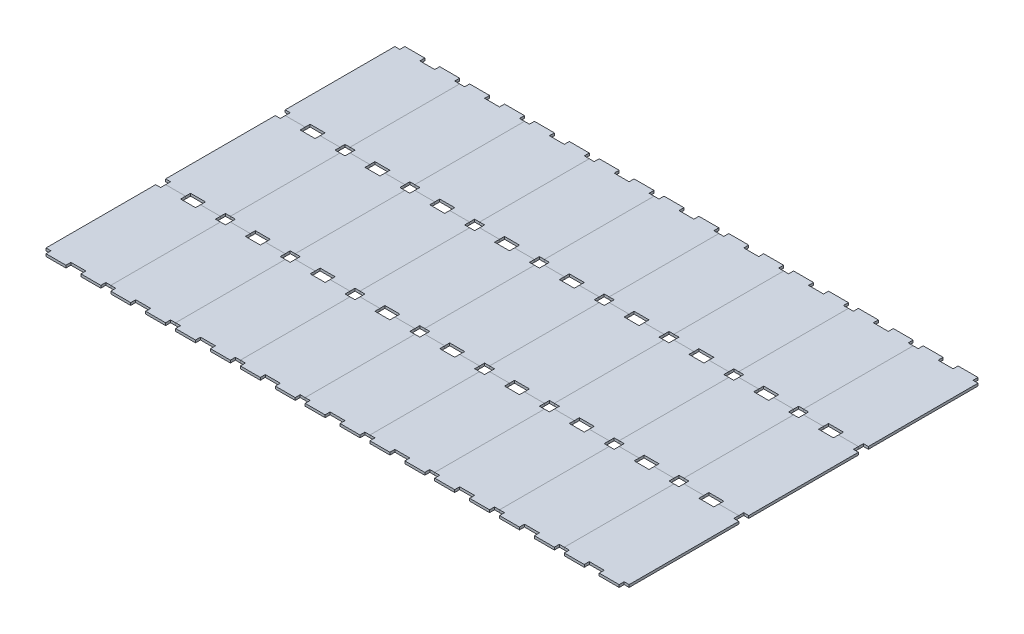
from build123d import *

# Parameters (mm, degrees)
SKETCH1_W           = 82.55
SKETCH1_H           = 152.4
BOSS_EXTRUDE1_DEPTH = 3.175
SKETCH2_W           = 6.35
SKETCH2_H           = 6.35
SKETCH2_W_2         = 9.525
CUT_EXTRUDE1_DEPTH  = 4.175
LPATTERN1_COUNT     = 9
LPATTERN1_PITCH     = 82.55
LPATTERN1_2_COUNT   = 3
LPATTERN1_2_PITCH   = 152.4


with BuildPart() as part:
    # Sketch1 → Boss-Extrude1 (new body)
    with BuildSketch(Plane(origin=(0, 0, 0), x_dir=(1, 0, 0), z_dir=(0, 1, 0))):
        Rectangle(SKETCH1_W, SKETCH1_H)
    extrude(amount=BOSS_EXTRUDE1_DEPTH)

    # Sketch2 → Cut-Extrude1 (cut, through all)
    with BuildSketch(Plane(origin=(0, 3.175, 0), x_dir=(1, 0, 0), z_dir=(0, 1, 0))):
        with Locations((-38.1, -73.025)):
            Rectangle(SKETCH2_W, SKETCH2_H)
        with Locations((-4.7625, -73.025)):
            Rectangle(SKETCH2_W_2, SKETCH2_H)
        with Locations((4.7625, -73.025)):
            Rectangle(SKETCH2_W_2, SKETCH2_H)
        with Locations((38.1, -73.025)):
            Rectangle(SKETCH2_W, SKETCH2_H)
    cut_extrude1 = extrude(amount=-CUT_EXTRUDE1_DEPTH, mode=Mode.SUBTRACT)

    # Mirror1: Cut-Extrude1 across plane
    add(cut_extrude1.mirror(Plane.XY), mode=Mode.SUBTRACT)


with BuildPart() as lpattern1_1:
    # LPattern1: pattern copy
    add(part.part.moved(Location(Vector(1, 0, 0) * (1 * LPATTERN1_PITCH))))


with BuildPart() as lpattern1_2:
    # LPattern1: pattern copy
    add(part.part.moved(Location(Vector(1, 0, 0) * (2 * LPATTERN1_PITCH))))


with BuildPart() as lpattern1_3:
    # LPattern1: pattern copy
    add(part.part.moved(Location(Vector(1, 0, 0) * (3 * LPATTERN1_PITCH))))


with BuildPart() as lpattern1_4:
    # LPattern1: pattern copy
    add(part.part.moved(Location(Vector(1, 0, 0) * (4 * LPATTERN1_PITCH))))


with BuildPart() as lpattern1_5:
    # LPattern1: pattern copy
    add(part.part.moved(Location(Vector(1, 0, 0) * (5 * LPATTERN1_PITCH))))


with BuildPart() as lpattern1_6:
    # LPattern1: pattern copy
    add(part.part.moved(Location(Vector(1, 0, 0) * (6 * LPATTERN1_PITCH))))


with BuildPart() as lpattern1_7:
    # LPattern1: pattern copy
    add(part.part.moved(Location(Vector(1, 0, 0) * (7 * LPATTERN1_PITCH))))


with BuildPart() as lpattern1_8:
    # LPattern1: pattern copy
    add(part.part.moved(Location(Vector(1, 0, 0) * (8 * LPATTERN1_PITCH))))


with BuildPart() as lpattern1_2_1:
    # LPattern1 2: pattern copy
    add(part.part.moved(Location(Vector(0, 0, 1) * (1 * LPATTERN1_2_PITCH))))


with BuildPart() as lpattern1_2_2:
    # LPattern1 2: pattern copy
    add(part.part.moved(Location(Vector(0, 0, 1) * (2 * LPATTERN1_2_PITCH))))


with BuildPart() as lpattern1_2_3:
    # LPattern1 2: pattern copy
    add(lpattern1_1.part.moved(Location(Vector(0, 0, 1) * (1 * LPATTERN1_2_PITCH))))


with BuildPart() as lpattern1_2_4:
    # LPattern1 2: pattern copy
    add(lpattern1_1.part.moved(Location(Vector(0, 0, 1) * (2 * LPATTERN1_2_PITCH))))


with BuildPart() as lpattern1_2_5:
    # LPattern1 2: pattern copy
    add(lpattern1_2.part.moved(Location(Vector(0, 0, 1) * (1 * LPATTERN1_2_PITCH))))


with BuildPart() as lpattern1_2_6:
    # LPattern1 2: pattern copy
    add(lpattern1_2.part.moved(Location(Vector(0, 0, 1) * (2 * LPATTERN1_2_PITCH))))


with BuildPart() as lpattern1_2_7:
    # LPattern1 2: pattern copy
    add(lpattern1_3.part.moved(Location(Vector(0, 0, 1) * (1 * LPATTERN1_2_PITCH))))


with BuildPart() as lpattern1_2_8:
    # LPattern1 2: pattern copy
    add(lpattern1_3.part.moved(Location(Vector(0, 0, 1) * (2 * LPATTERN1_2_PITCH))))


with BuildPart() as lpattern1_2_9:
    # LPattern1 2: pattern copy
    add(lpattern1_4.part.moved(Location(Vector(0, 0, 1) * (1 * LPATTERN1_2_PITCH))))


with BuildPart() as lpattern1_2_10:
    # LPattern1 2: pattern copy
    add(lpattern1_4.part.moved(Location(Vector(0, 0, 1) * (2 * LPATTERN1_2_PITCH))))


with BuildPart() as lpattern1_2_11:
    # LPattern1 2: pattern copy
    add(lpattern1_5.part.moved(Location(Vector(0, 0, 1) * (1 * LPATTERN1_2_PITCH))))


with BuildPart() as lpattern1_2_12:
    # LPattern1 2: pattern copy
    add(lpattern1_5.part.moved(Location(Vector(0, 0, 1) * (2 * LPATTERN1_2_PITCH))))


with BuildPart() as lpattern1_2_13:
    # LPattern1 2: pattern copy
    add(lpattern1_6.part.moved(Location(Vector(0, 0, 1) * (1 * LPATTERN1_2_PITCH))))


with BuildPart() as lpattern1_2_14:
    # LPattern1 2: pattern copy
    add(lpattern1_6.part.moved(Location(Vector(0, 0, 1) * (2 * LPATTERN1_2_PITCH))))


with BuildPart() as lpattern1_2_15:
    # LPattern1 2: pattern copy
    add(lpattern1_7.part.moved(Location(Vector(0, 0, 1) * (1 * LPATTERN1_2_PITCH))))


with BuildPart() as lpattern1_2_16:
    # LPattern1 2: pattern copy
    add(lpattern1_7.part.moved(Location(Vector(0, 0, 1) * (2 * LPATTERN1_2_PITCH))))


with BuildPart() as lpattern1_2_17:
    # LPattern1 2: pattern copy
    add(lpattern1_8.part.moved(Location(Vector(0, 0, 1) * (1 * LPATTERN1_2_PITCH))))


with BuildPart() as lpattern1_2_18:
    # LPattern1 2: pattern copy
    add(lpattern1_8.part.moved(Location(Vector(0, 0, 1) * (2 * LPATTERN1_2_PITCH))))


solid = Compound([part.part, lpattern1_1.part, lpattern1_2.part, lpattern1_3.part, lpattern1_4.part, lpattern1_5.part, lpattern1_6.part, lpattern1_7.part, lpattern1_8.part, lpattern1_2_1.part, lpattern1_2_2.part, lpattern1_2_3.part, lpattern1_2_4.part, lpattern1_2_5.part, lpattern1_2_6.part, lpattern1_2_7.part, lpattern1_2_8.part, lpattern1_2_9.part, lpattern1_2_10.part, lpattern1_2_11.part, lpattern1_2_12.part, lpattern1_2_13.part, lpattern1_2_14.part, lpattern1_2_15.part, lpattern1_2_16.part, lpattern1_2_17.part, lpattern1_2_18.part])
